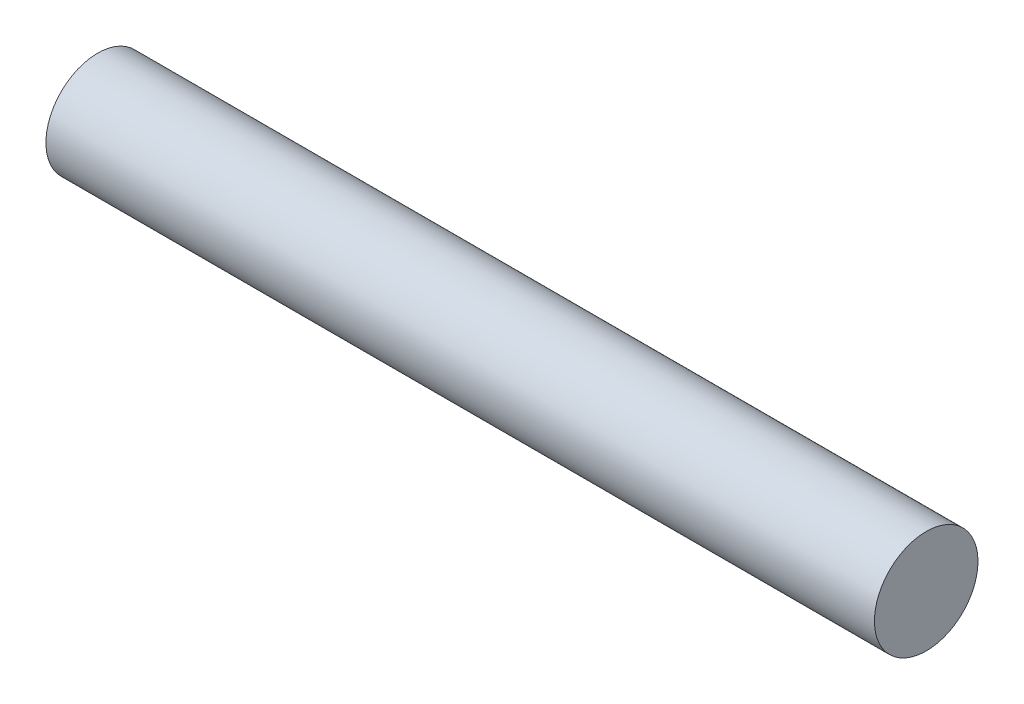
from build123d import *

# Parameters (mm, degrees)
SKETCH1_R           = 25
BOSS_EXTRUDE1_DEPTH = 400


with BuildPart() as part:
    # Sketch1 → Boss-Extrude1 (new body)
    with BuildSketch(Plane(origin=(0, 0, 0), x_dir=(0, 0, -1), z_dir=(1, 0, 0))):
        Circle(SKETCH1_R)
    extrude(amount=BOSS_EXTRUDE1_DEPTH)


solid = part.part
